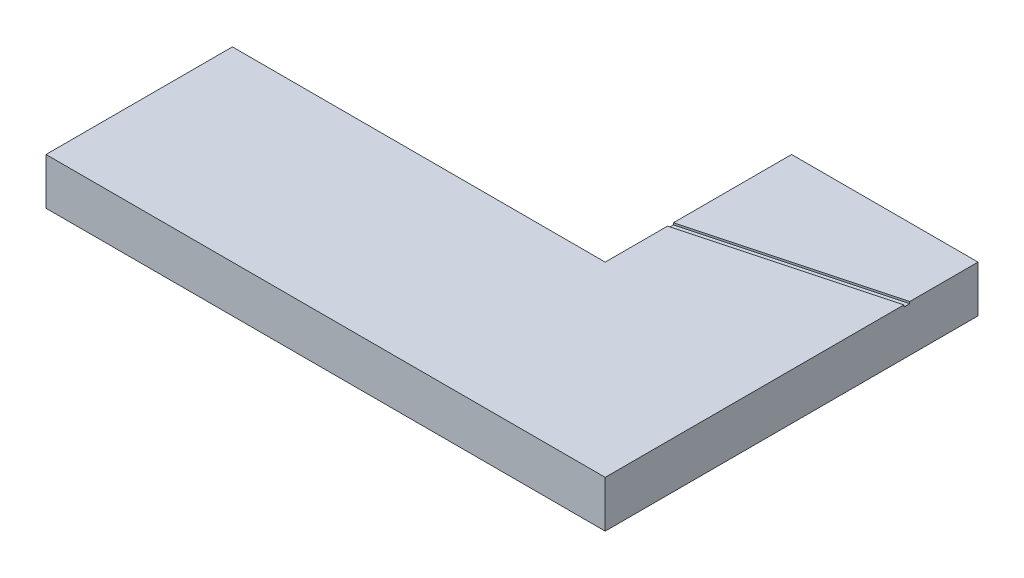
from build123d import *

# Parameters (mm, degrees)
BOSS_EXTRUDE1_DEPTH = 25
CUT_EXTRUDE1_DEPTH  = 1


with BuildPart() as part:
    # Sketch1 → Boss-Extrude1 (new body)
    with BuildSketch(Plane(origin=(0, 0, 0), x_dir=(1, 0, 0), z_dir=(0, 1, 0))):
        Polygon((0, 0), (0, 100), (100, 100), (100, -100), (-200, -100), (-200, 0), align=None)
    extrude(amount=BOSS_EXTRUDE1_DEPTH)

    # Sketch2 → Cut-Extrude1 (cut)
    with BuildSketch(Plane(origin=(0, 25, 0), x_dir=(1, 0, 0), z_dir=(0, 1, 0))):
        Polygon((150.414178645, 73.750443427), (-91.067277928, 9.045682152), (-91.843735063, 11.943459631), (149.637721509, 76.648220906), align=None)
    extrude(amount=-CUT_EXTRUDE1_DEPTH, mode=Mode.SUBTRACT)


solid = part.part
